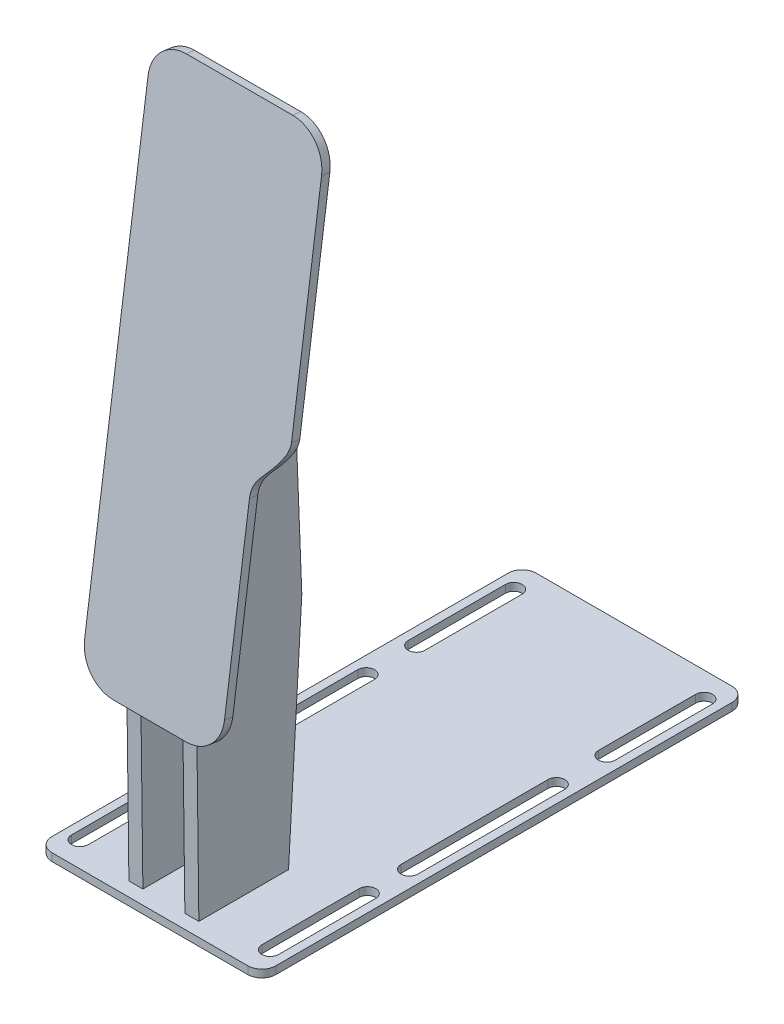
from build123d import *

# Parameters (mm, degrees)
SKETCH1_R           = 7.112045721
BOSS_EXTRUDE1_DEPTH = 2.75
BOSS_EXTRUDE2_DEPTH = 3
BOSS_EXTRUDE3_DEPTH = 2.5


with BuildPart() as part:
    # Sketch1 → Boss-Extrude1 (new body)
    with BuildSketch(Plane(origin=(0, 0, 0), x_dir=(1, 0, 0), z_dir=(0, 1, 0))):
        with BuildLine():
            Line((-35, 86.51875), (35, 86.51875))
            ThreePointArc((35, 86.51875), (38.535533906, 85.054283906), (40, 81.51875))
            Line((40, 81.51875), (40, -81.51875))
            ThreePointArc((40, -81.51875), (38.535533906, -85.054283906), (35, -86.51875))
            Line((35, -86.51875), (-35, -86.51875))
            ThreePointArc((-35, -86.51875), (-38.535533906, -85.054283906), (-40, -81.51875))
            Line((-40, -81.51875), (-40, 81.51875))
            ThreePointArc((-40, 81.51875), (-38.535533906, 85.054283906), (-35, 86.51875))
        make_face()
        with Locations((0, -48.920084539)):
            Circle(SKETCH1_R, mode=Mode.SUBTRACT)
        with BuildLine():
            Line((37, 77.51875), (37, 42.76875))
            ThreePointArc((37, 42.76875), (34, 39.76875), (31, 42.76875))
            Line((31, 42.76875), (31, 77.51875))
            ThreePointArc((31, 77.51875), (34, 80.51875), (37, 77.51875))
        make_face(mode=Mode.SUBTRACT)
        with BuildLine():
            Line((-37, 77.51875), (-37, 42.76875))
            ThreePointArc((-37, 42.76875), (-34, 39.76875), (-31, 42.76875))
            Line((-31, 42.76875), (-31, 77.51875))
            ThreePointArc((-31, 77.51875), (-34, 80.51875), (-37, 77.51875))
        make_face(mode=Mode.SUBTRACT)
        with BuildLine():
            Line((37, -77.51875), (37, -42.76875))
            ThreePointArc((37, -42.76875), (34, -39.76875), (31, -42.76875))
            Line((31, -42.76875), (31, -77.51875))
            ThreePointArc((31, -77.51875), (34, -80.51875), (37, -77.51875))
        make_face(mode=Mode.SUBTRACT)
        with BuildLine():
            Line((-37, -77.51875), (-37, -42.76875))
            ThreePointArc((-37, -42.76875), (-34, -39.76875), (-31, -42.76875))
            Line((-31, -42.76875), (-31, -77.51875))
            ThreePointArc((-31, -77.51875), (-34, -80.51875), (-37, -77.51875))
        make_face(mode=Mode.SUBTRACT)
        with BuildLine():
            Line((37, 24.76875), (37, -27.76875))
            ThreePointArc((37, -27.76875), (34, -30.76875), (31, -27.76875))
            Line((31, -27.76875), (31, 24.76875))
            ThreePointArc((31, 24.76875), (34, 27.76875), (37, 24.76875))
        make_face(mode=Mode.SUBTRACT)
        with BuildLine():
            Line((-37, 24.76875), (-37, -27.76875))
            ThreePointArc((-37, -27.76875), (-34, -30.76875), (-31, -27.76875))
            Line((-31, -27.76875), (-31, 24.76875))
            ThreePointArc((-31, 24.76875), (-34, 27.76875), (-37, 24.76875))
        make_face(mode=Mode.SUBTRACT)
    extrude(amount=BOSS_EXTRUDE1_DEPTH)



with BuildPart() as body_2:
    # Sketch3 → Boss-Extrude2 (new body)
    with BuildSketch(Plane(origin=(0, 12.958063193, 93.198377578), x_dir=(0, -0.990472215, 0.137712714), z_dir=(0, 0.137712714, 0.990472215))):
        with BuildLine():
            Line((-125.30290794, 25), (-60.504073198, 25))
            ThreePointArc((-60.504073198, 25), (-52.018791824, 21.485281374), (-48.504073198, 13))
            Line((-48.504073198, 13), (-48.504073198, -13))
            ThreePointArc((-48.504073198, -13), (-52.018791824, -21.485281374), (-60.504073198, -25))
            Line((-60.504073198, -25), (-225.30290794, -25))
            ThreePointArc((-225.30290794, -25), (-233.788189314, -21.485281374), (-237.30290794, -13))
            Line((-237.30290794, -13), (-237.30290794, 25))
            ThreePointArc((-237.30290794, 25), (-233.788189314, 33.485281374), (-225.30290794, 37))
            Line((-225.30290794, 37), (-147.30290794, 37))
            add(Edge.make_bspline(
                [(-147.30290794, 37), (-144.065512893, 37), (-135.5827842, 31), (-129.980550468, 25), (-125.30290794, 25)],
                knots=[0, 0, 0, 0, 0.5, 1, 1, 1, 1], degree=3))
        make_face()
    extrude(amount=-BOSS_EXTRUDE2_DEPTH)


with BuildPart() as part_1:
    add(part.part)

    add(body_2.part)  # Boss-Extrude3 merges body 2
    # Sketch4 → Boss-Extrude3 (add, symmetric)
    with BuildSketch(Plane(origin=(10, 0, 0), x_dir=(0, 0, -1), z_dir=(1, 0, 0))):
        Polygon((-59.513534896, 233.445335393), (-50.513534896, 232.678056605), (-44.72786756, 85.636126776), (-49.474356372, 2.75), (-81.51875, 2.75), (-82.335595034, 69.302056709), align=None)
    boss_extrude3 = extrude(amount=BOSS_EXTRUDE3_DEPTH, both=True)

    # Mirror1: Boss-Extrude3 across plane
    add(boss_extrude3.mirror(Plane(origin=(0, 0, 0), x_dir=(0, 0, 1), z_dir=(1, 0, 0))))


solid = part_1.part
